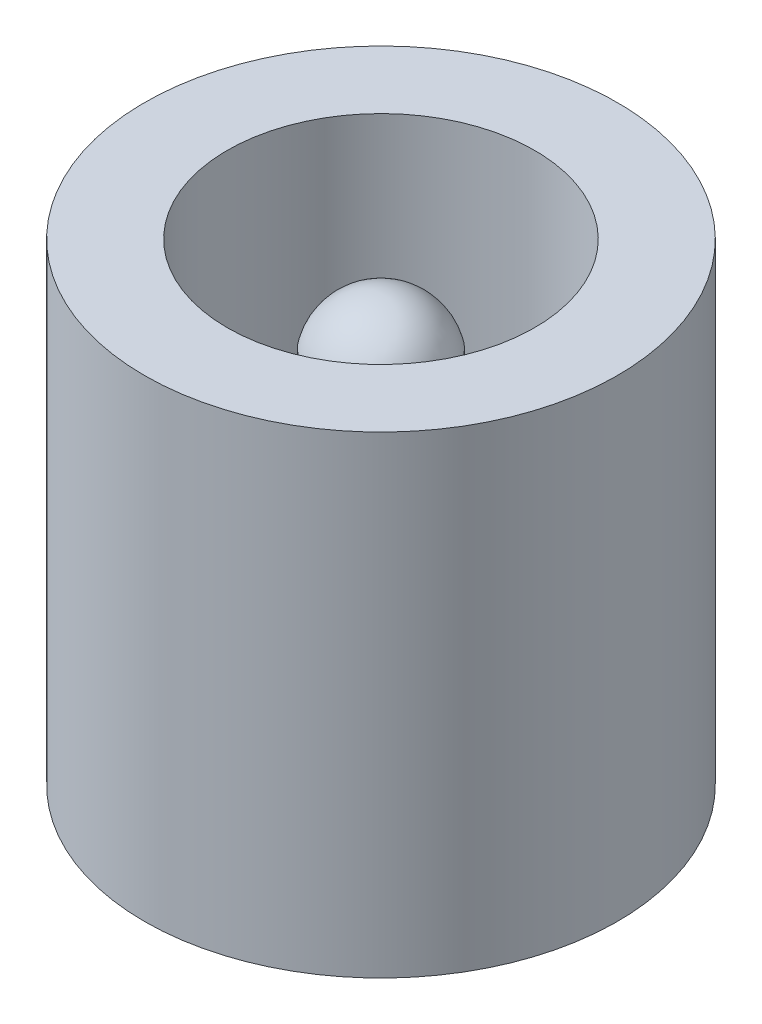
from build123d import *

# Parameters (mm, degrees)
SKETCH1_R           = 5
BOSS_EXTRUDE1_DEPTH = 10
SKETCH2_R           = 3.25
CUT_EXTRUDE1_DEPTH  = 8
SKETCH3_R           = 1.25
BOSS_EXTRUDE2_DEPTH = 6
DOME1_FACE_RADIUS   = 1.25
DOME1_HEIGHT        = 1


with BuildPart() as part:
    # Sketch1 → Boss-Extrude1 (new body)
    with BuildSketch(Plane(origin=(0, 0, 0), x_dir=(1, 0, 0), z_dir=(0, 1, 0))):
        Circle(SKETCH1_R)
    extrude(amount=BOSS_EXTRUDE1_DEPTH)

    # Sketch2 → Cut-Extrude1 (cut)
    with BuildSketch(Plane(origin=(0, 10, 0), x_dir=(1, 0, 0), z_dir=(0, 1, 0))):
        Circle(SKETCH2_R)
    extrude(amount=-CUT_EXTRUDE1_DEPTH, mode=Mode.SUBTRACT)

    # Sketch3 → Boss-Extrude2 (add)
    with BuildSketch(Plane(origin=(0, 2, 0), x_dir=(1, 0, 0), z_dir=(0, 1, 0))):
        Circle(SKETCH3_R)
    extrude(amount=BOSS_EXTRUDE2_DEPTH)

    # Dome1: a dome of height H over a round flat face of radius A is a cap of a sphere of radius (A * A + H * H) / (2 * H)
    dome1_r = (DOME1_FACE_RADIUS * DOME1_FACE_RADIUS + DOME1_HEIGHT * DOME1_HEIGHT) / (2 * DOME1_HEIGHT)
    dome1_base = Plane((0, 8, 0), z_dir=(0, 1, 0))
    with Locations(dome1_base.offset(DOME1_HEIGHT - dome1_r)):
        dome1_ball = Sphere(dome1_r, mode=Mode.PRIVATE)
    add(split(dome1_ball, bisect_by=dome1_base, keep=Keep.TOP, mode=Mode.PRIVATE))


solid = part.part
